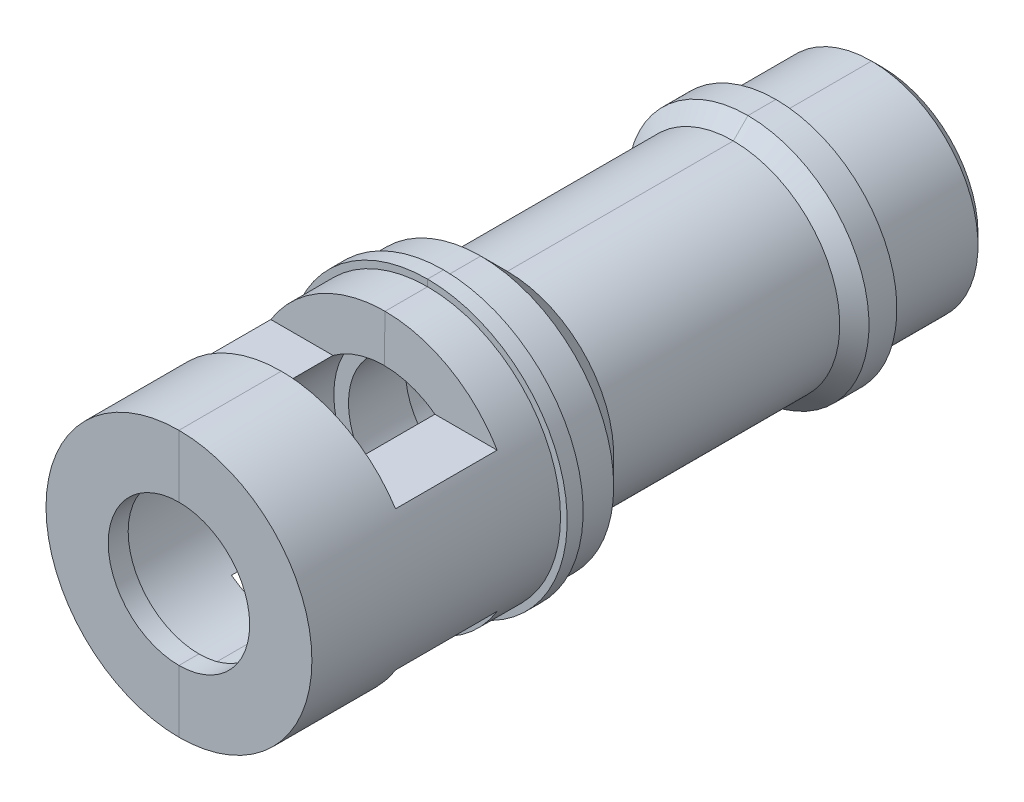
from build123d import *

# Parameters (mm, degrees)
CUT_EXTRUDE1_DEPTH      = 11.5
CUT_EXTRUDE1_DEPTH_BACK = 11.5
CUT_EXTRUDE2_START      = -52.9
SKETCH4_W               = 1.9
SKETCH4_H               = 13.4
CUT_EXTRUDE2_DEPTH      = 11.80355


with BuildPart() as part:
    # Sketch1 → Revolve1 (revolve)
    with BuildSketch(Plane(origin=(0, 0, 0), x_dir=(0, 0, -1), z_dir=(1, 0, 0))):
        Polygon((0, -10), (18.7, -10), (18.7, -10.5), (19.9, -10.5), (19.9, -10), (22.7, -10), (24.7, -8), (41.7, -8), (42.8, -9.1), (44.9, -9.1), (44.919200571, -8), (52.1, -8), (52.9, -7.2), (52.9, -6.5), (41.09645045, -6.5), (41.09645045, -5.5), (39.09645045, -5.5), (39.09645045, -6.5), (22.448200248, -6.5), (22.448200248, -5.419751362), (18.148250202, -5.399024551), (18.148250202, -6.5), (1.5, -6.5), (1.5, -5.318775912), (0, -5.318775912), align=None)
    revolve(axis=Axis((0, 0, -52.9), (0, 0, 1)))

    # Sketch3 → Cut-Extrude1 (cut, two sides)
    with BuildSketch(Plane(origin=(0, 0, 0), x_dir=(0, 0, -1), z_dir=(1, 0, 0))) as cut_extrude1_sk:
        Polygon((7.780799429, -5.25), (7.581057749, -16.693193187), (15.618942251, -16.693193187), (15.419200571, -5.25), align=None)
        Polygon((7.581057749, 16.693193187), (15.618942251, 16.693193187), (15.419200571, 5.25), (7.780799429, 5.25), align=None)
    extrude(amount=CUT_EXTRUDE1_DEPTH, mode=Mode.SUBTRACT)
    extrude(cut_extrude1_sk.sketch, amount=-CUT_EXTRUDE1_DEPTH_BACK, mode=Mode.SUBTRACT)

    # Sketch4 → Cut-Extrude2 (cut)
    with BuildSketch(Plane.XY.offset(CUT_EXTRUDE2_START)):
        with Locations((0, 0.012903397)):
            Rectangle(SKETCH4_W, SKETCH4_H)
    extrude(amount=CUT_EXTRUDE2_DEPTH, mode=Mode.SUBTRACT)


with BuildPart() as body_2:
    # Split1: the piece on the far side of the plane
    add(part.part)
    split(bisect_by=Plane(origin=(0, 0, 0), x_dir=(0, 0, 1), z_dir=(1, 0, 0)), keep=Keep.BOTTOM)


with BuildPart() as part_1:
    add(part.part)

    # Split1
    split(bisect_by=Plane(origin=(0, 0, 0), x_dir=(0, 0, 1), z_dir=(1, 0, 0)), keep=Keep.TOP)


solid = Compound([body_2.part, part_1.part])
